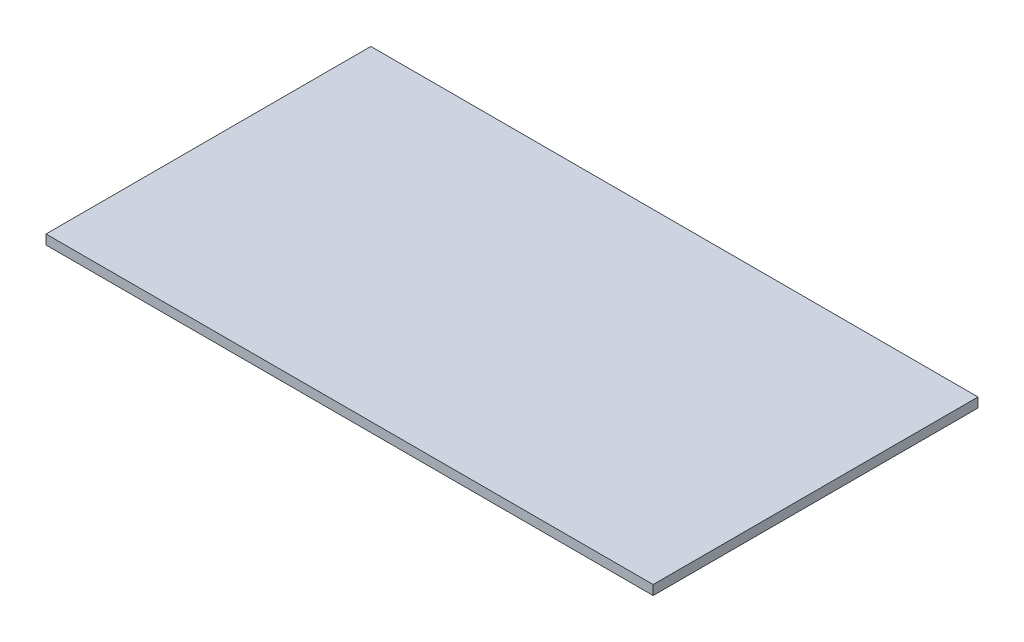
from build123d import *

# Parameters (mm, degrees)
BOSS_EXTRUDE1_DEPTH = 0.25


with BuildPart() as part:
    # Sketch1 → Boss-Extrude1 (new body)
    with BuildSketch(Plane(origin=(0, 0, 0), x_dir=(1, 0, 0), z_dir=(0, 1, 0))):
        Polygon((7.898, 4.24), (0, 4.24), (-7.952, 4.24), (-7.952, -4.24), (7.898, -4.24), align=None)
    extrude(amount=BOSS_EXTRUDE1_DEPTH)


solid = part.part
